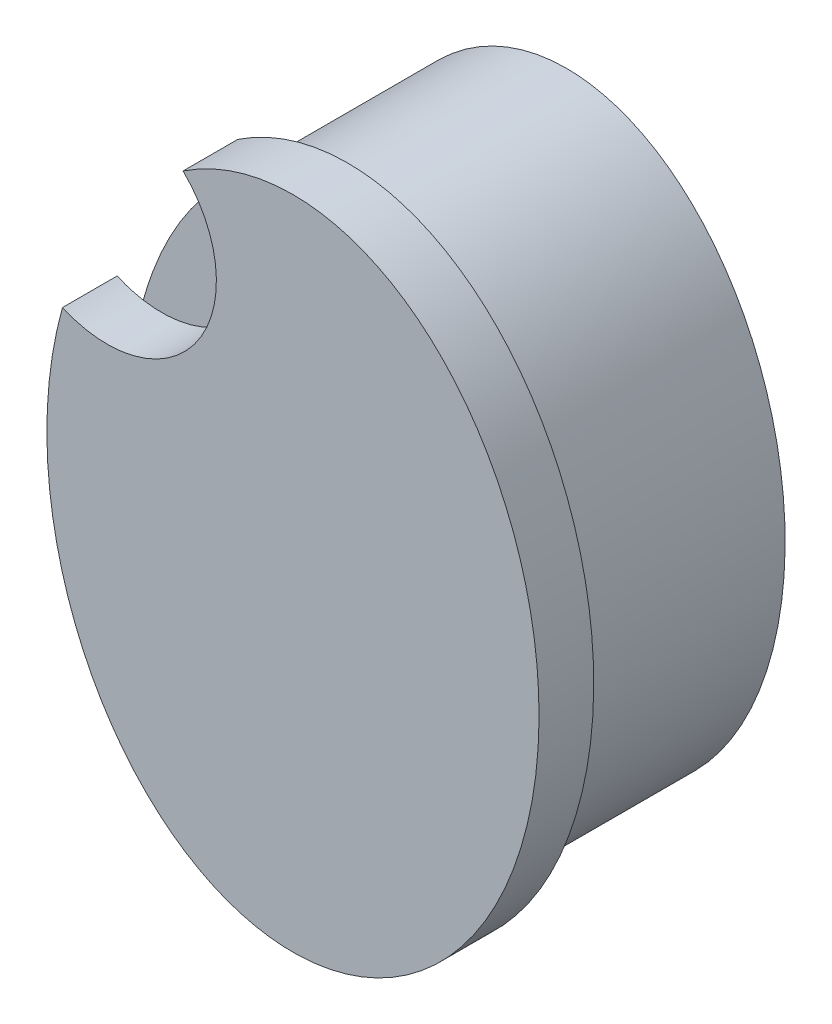
from build123d import *

# Parameters (mm, degrees)
CROQUIS1_RX             = 11
CROQUIS1_RY             = 8
SALIENTE_EXTRUIR1_DEPTH = 8
CROQUIS2_RX             = 12
CROQUIS2_RY             = 9
SALIENTE_EXTRUIR2_DEPTH = 2
CROQUIS3_R              = 4
CORTAR_EXTRUIR1_DEPTH   = 2


with BuildPart() as part:
    # Croquis1 → Saliente-Extruir1 (new body)
    with BuildSketch(Plane.XY):
        with Locations(Location((0, 0), (0, 0, 90))):
            Ellipse(CROQUIS1_RX, CROQUIS1_RY)
    extrude(amount=SALIENTE_EXTRUIR1_DEPTH)

    # Croquis2 → Saliente-Extruir2 (add)
    with BuildSketch(Plane.XY.offset(8)):
        with Locations(Location((0, 0), (0, 0, 90))):
            Ellipse(CROQUIS2_RX, CROQUIS2_RY)
    extrude(amount=SALIENTE_EXTRUIR2_DEPTH)

    # Croquis3 → Cortar-Extruir1 (cut)
    with BuildSketch(Plane.XY.offset(10)):
        with Locations((-6.800291845, 7.860566089)):
            Circle(CROQUIS3_R)
    extrude(amount=-CORTAR_EXTRUIR1_DEPTH, mode=Mode.SUBTRACT)


solid = part.part
